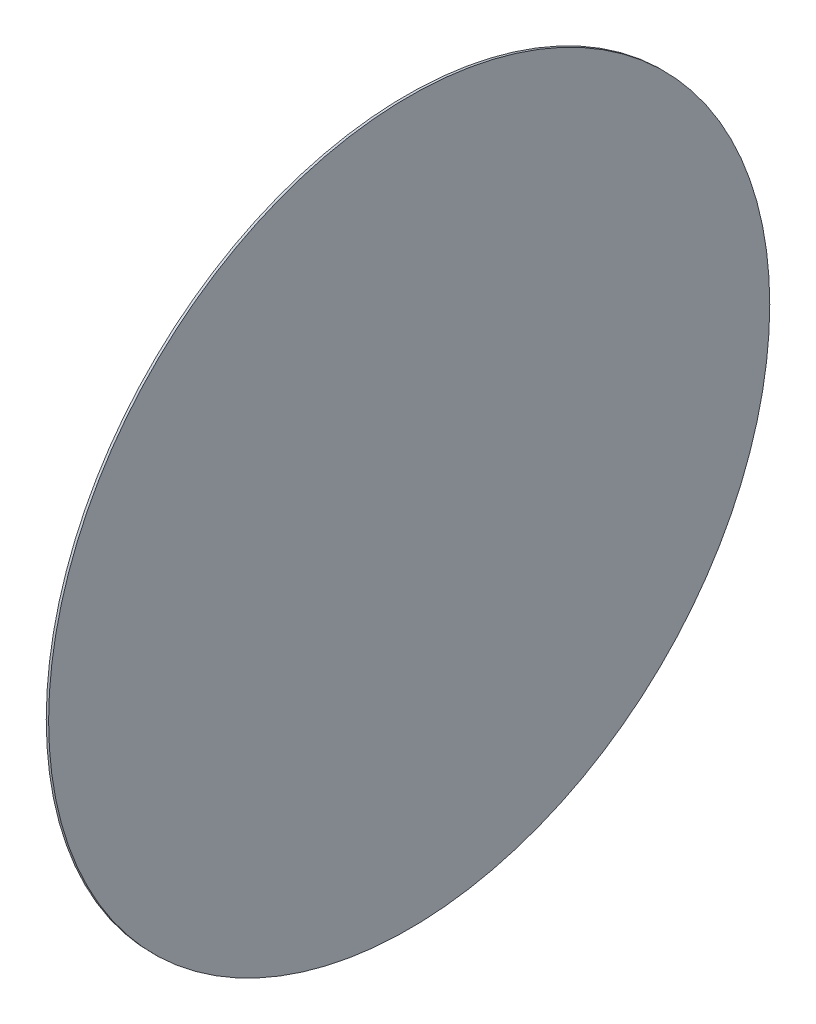
from build123d import *

# Parameters (mm, degrees)
SKETCH_1_W = 0.059
SKETCH_1_H = 9


with BuildPart() as part:
    # 草图1 → 旋转2 (revolve)
    with BuildSketch(Plane.XY, mode=Mode.PRIVATE) as revolve_2_sk:
        with Locations((0.0295, 4.5)):
            Rectangle(SKETCH_1_W, SKETCH_1_H)
    revolve(revolve_2_sk.sketch.rotate(Axis((0, 0, 0), (1, 0, 0)), 90), axis=Axis((0, 0, 0), (1, 0, 0)))  # turned: the seam where the file's is


solid = part.part
